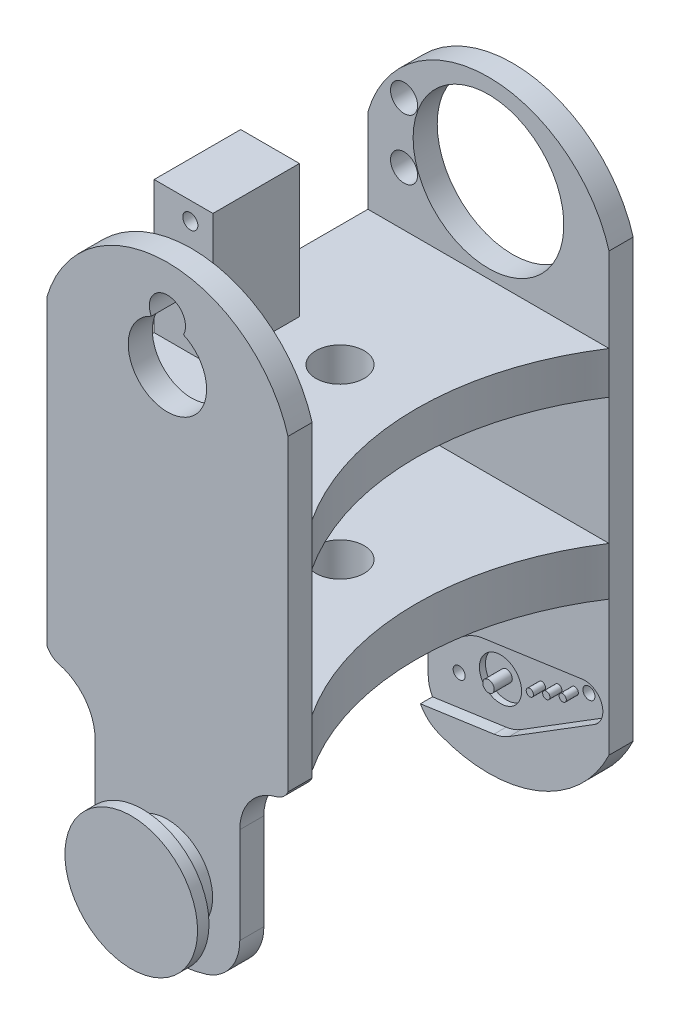
from build123d import *

# Parameters (mm, degrees)
SKETCH1_W                = 21
SKETCH1_H                = 49.25
BOSS_EXTRUDE1_DEPTH      = 20
SKETCH4_R                = 7.5
BOSS_EXTRUDE2_DEPTH      = 6
BOSS_EXTRUDE2_DEPTH_BACK = 63.25
SKETCH2_W                = 50
SKETCH2_H                = 112.412407925
SKETCH2_R                = 12.5
CUT_EXTRUDE1_DEPTH       = 110.803517703
CUT_EXTRUDE1_DEPTH_BACK  = 110.803517703
SKETCH5_W                = 20
SKETCH5_H                = 49.25
CUT_EXTRUDE2_DEPTH       = 103.250382029
CUT_EXTRUDE3_DEPTH       = 110.803517703
SKETCH7_W                = 9.75
SKETCH7_H                = 14.35
BOSS_EXTRUDE3_DEPTH      = 22
CUT_EXTRUDE4_REACH       = 99.528
SKETCH8_R                = 1.25
SKETCH9_R                = 2.25
CUT_EXTRUDE5_DEPTH       = 26.4
SKETCH10_R               = 0.6
SKETCH10_R_2             = 0.95
CUT_EXTRUDE6_DEPTH       = 2
SKETCH17_R               = 3.5
SKETCH17_R_2             = 0.95
CUT_EXTRUDE11_DEPTH      = 1
SKETCH11_R               = 1
CUT_EXTRUDE7_DEPTH       = 2
CUT_EXTRUDE8_DEPTH       = 4
CUT_EXTRUDE9_DEPTH       = 82.485524021
SKETCH14_R               = 12.5
SKETCH14_R_2             = 6.5
BOSS_EXTRUDE4_DEPTH      = 4
SKETCH16_R               = 3
CUT_EXTRUDE10_DEPTH      = 4
SKETCH18_R               = 11
BOSS_EXTRUDE5_DEPTH      = 1.9
SKETCH19_R               = 11
BOSS_EXTRUDE6_DEPTH      = 1.9
SKETCH20_R               = 4
CUT_EXTRUDE12_DEPTH      = 75
SKETCH22_R               = 45
CUT_EXTRUDE14_DEPTH      = 8


with BuildPart() as part:
    # Sketch1 → Boss-Extrude1 (new, symmetric)
    with BuildSketch(Plane.YZ):
        Polygon((-12.5, 24.625), (-12.5, 28.625), (87.5, 28.625), (87.5, 24.625), (58.5, 24.625), (58.5, -24.625), (87.5, -24.625), (87.5, -28.625), (-12.5, -28.625), (-12.5, -24.625), (22.5, -24.625), (22.5, 24.625), align=None)
        with Locations((41, 0)):
            Rectangle(SKETCH1_W, SKETCH1_H, mode=Mode.SUBTRACT)
    extrude(amount=BOSS_EXTRUDE1_DEPTH, both=True)

    # Sketch4 → Boss-Extrude2 (add, two sides)
    with BuildSketch(Plane(origin=(0, 0, -28.625), x_dir=(1, 0, 0), z_dir=(0, 0, -1))) as boss_extrude2_sk:
        with Locations(Location((0, 0, 0), (0, 0, 180))):
            Circle(SKETCH4_R)
    extrude(amount=BOSS_EXTRUDE2_DEPTH)
    extrude(boss_extrude2_sk.sketch, amount=-BOSS_EXTRUDE2_DEPTH_BACK)

    # Sketch2 → Cut-Extrude1 (cut, two sides)
    with BuildSketch(Plane(origin=(0, 0, -28.625), x_dir=(1, 0, 0), z_dir=(0, 0, -1))) as cut_extrude1_sk:
        with Locations((0, -36.293796038)):
            Rectangle(SKETCH2_W, SKETCH2_H)
        with BuildLine():
            Line((20, -0.087592075), (20, -72.5))
            ThreePointArc((20, -72.5), (0, -87.5), (-20, -72.5))
            Line((-20, -72.5), (-20, -0.087592075))
            ThreePointArc((-20, -0.087592075), (0, 12.5), (20, -0.087592075))
        make_face(mode=Mode.SUBTRACT)
        with Locations(Location((0, -72.5, 0), (0, 0, 270))):
            Circle(SKETCH2_R)
    extrude(amount=CUT_EXTRUDE1_DEPTH, mode=Mode.SUBTRACT)
    extrude(cut_extrude1_sk.sketch, amount=-CUT_EXTRUDE1_DEPTH_BACK, mode=Mode.SUBTRACT)

    # Sketch5 → Cut-Extrude2 (cut, through all)
    with BuildSketch(Plane.YZ.offset(20)):
        Rectangle(SKETCH5_W, SKETCH5_H)
    extrude(amount=-CUT_EXTRUDE2_DEPTH, mode=Mode.SUBTRACT)

    # Sketch6 → Cut-Extrude3 (cut, through all)
    with BuildSketch(Plane(origin=(0, 0, -28.625), x_dir=(1, 0, 0), z_dir=(0, 0, -1))):
        with BuildLine():
            Line((-12, 5.343628911), (-12, -13.048253679))
            ThreePointArc((-12, -13.048253679), (-13.67544468, -17.947233164), (-18, -20.794220371))
            ThreePointArc((-18, -20.794220371), (-19.196771953, -21.416398141), (-20, -22.5))
            Line((-20, -22.5), (-20, 15.418169496))
            Line((-20, 15.418169496), (0, 15.418169496))
            Line((0, 15.418169496), (0, 12.5))
            ThreePointArc((0, 12.5), (-4.185625792, 12.101526483), (-8.220875011, 10.92042185))
            ThreePointArc((-8.220875011, 10.92042185), (-10.966225922, 8.711952128), (-12, 5.343628911))
        make_face()
    extrude(amount=-CUT_EXTRUDE3_DEPTH, mode=Mode.SUBTRACT)

    # Sketch7 → Boss-Extrude3 (add)
    with BuildSketch(Plane(origin=(0, 58.5, 0), x_dir=(-1, 0, 0), z_dir=(0, 1, 0))):
        with Locations((15.125, 3.65)):
            Rectangle(SKETCH7_W, SKETCH7_H)
    extrude(amount=BOSS_EXTRUDE3_DEPTH)

    # Sketch8 → Cut-Extrude4 (cut, up to next)
    with BuildSketch(Plane(origin=(0, 0, -3.525), x_dir=(1, 0, 0), z_dir=(0, 0, -1)), mode=Mode.PRIVATE) as cut_extrude4_sk1:
        with Locations(Location((-14, -67.5, 0), (0, 0, 270))):
            Circle(SKETCH8_R)
    cut_extrude4_tool1 = extrude(cut_extrude4_sk1.sketch, amount=-CUT_EXTRUDE4_REACH, mode=Mode.PRIVATE) & part.part
    # Sketch8 → Cut-Extrude4 (cut, up to next)
    with BuildSketch(Plane(origin=(0, 0, -3.525), x_dir=(1, 0, 0), z_dir=(0, 0, -1)), mode=Mode.PRIVATE) as cut_extrude4_sk2:
        with Locations(Location((-14, -77.5, 0), (0, 0, 270))):
            Circle(SKETCH8_R)
    cut_extrude4_tool2 = extrude(cut_extrude4_sk2.sketch, amount=-CUT_EXTRUDE4_REACH, mode=Mode.PRIVATE) & part.part
    add(cut_extrude4_tool1.solids().sort_by_distance((-14, 67.5, -3.525))[0], mode=Mode.SUBTRACT)
    add(cut_extrude4_tool2.solids().sort_by_distance((-14, 77.5, -3.525))[0], mode=Mode.SUBTRACT)

    # Sketch9 → Cut-Extrude5 (cut)
    with BuildSketch(Plane(origin=(0, 0, -28.625), x_dir=(1, 0, 0), z_dir=(0, 0, -1))):
        with Locations(Location((-14, -77.5, 0), (0, 0, 180))):
            Circle(SKETCH9_R)
        with Locations(Location((-14, -67.5, 0), (0, 0, 90))):
            Circle(SKETCH9_R)
    extrude(amount=-CUT_EXTRUDE5_DEPTH, mode=Mode.SUBTRACT)

    # Sketch10 → Cut-Extrude6 (cut)
    with BuildSketch(Plane.XY.offset(-24.625)):
        with BuildLine():
            Line((-0.917974412, 6.434852211), (15.551094055, 8.784274226))
            ThreePointArc((15.551094055, 8.784274226), (18.793852416, 6.840402867), (17.559251818, 3.266906118))
            Line((17.559251818, 3.266906118), (3.433034074, -5.519445357))
            ThreePointArc((3.433034074, -5.519445357), (2.223130932, -6.108002035), (0.917974412, -6.434852211))
            Line((0.917974412, -6.434852211), (-15.551094055, -8.784274226))
            ThreePointArc((-15.551094055, -8.784274226), (-18.793852416, -6.840402867), (-17.559251818, -3.266906118))
            Line((-17.559251818, -3.266906118), (-3.433034074, 5.519445357))
            ThreePointArc((-3.433034074, 5.519445357), (-2.223130932, 6.108002035), (-0.917974412, 6.434852211))
        make_face()
        with Locations((12.309973332, 4.480463878)):
            Circle(SKETCH10_R, mode=Mode.SUBTRACT)
        with Locations((9.584864732, 3.488605462)):
            Circle(SKETCH10_R, mode=Mode.SUBTRACT)
        with Locations((6.859756132, 2.496747046)):
            Circle(SKETCH10_R, mode=Mode.SUBTRACT)
        Circle(SKETCH10_R_2, mode=Mode.SUBTRACT)
    extrude(amount=-CUT_EXTRUDE6_DEPTH, mode=Mode.SUBTRACT)

    # Sketch17 → Cut-Extrude11 (cut)
    with BuildSketch(Plane.XY.offset(-26.625)):
        Circle(SKETCH17_R)
        Circle(SKETCH17_R_2, mode=Mode.SUBTRACT)
    extrude(amount=-CUT_EXTRUDE11_DEPTH, mode=Mode.SUBTRACT)

    # Sketch11 → Cut-Extrude7 (cut)
    with BuildSketch(Plane.XY.offset(-26.625)):
        with Locations((14.659204884, 5.335514236)):
            Circle(SKETCH11_R)
        with Locations(Location((-6.859756132, -2.496747046, 0), (0, 0, 282.284944741))):
            Circle(SKETCH11_R)
    extrude(amount=-CUT_EXTRUDE7_DEPTH, mode=Mode.SUBTRACT)

    # Sketch12 → Cut-Extrude8 (cut)
    with BuildSketch(Plane.XY.offset(28.625)):
        with BuildLine():
            Line((0, -12.5), (0, -18.039119765))
            Line((0, -18.039119765), (20, -18.039119765))
            Line((20, -18.039119765), (20, 21.429096263))
            ThreePointArc((20, 21.429096263), (19.196193013, 20.360986537), (18.008206922, 19.748081074))
            ThreePointArc((18.008206922, 19.748081074), (13.678040469, 16.902328803), (12, 12))
            Line((12, 12), (12, -3.925954614))
            ThreePointArc((12, -3.925954614), (10.465352752, -8.637558778), (6.450196551, -11.541500351))
            ThreePointArc((6.450196551, -11.541500351), (3.264426341, -12.285407289), (0, -12.5))
        make_face()
    extrude(amount=-CUT_EXTRUDE8_DEPTH, mode=Mode.SUBTRACT)

    # Sketch13 → Cut-Extrude9 (cut, through all)
    with BuildSketch(Plane(origin=(0, 58.5, 0), x_dir=(-1, 0, 0), z_dir=(0, 1, 0))):
        with BuildLine():
            Line((-20, 24.625), (-20, -24.625))
            ThreePointArc((-20, -24.625), (-12.664431165, 0), (-20, 24.625))
        make_face()
    extrude(amount=-CUT_EXTRUDE9_DEPTH, mode=Mode.SUBTRACT)

    # Sketch14 → Boss-Extrude4 (add)
    with BuildSketch(Plane.XY.offset(28.625)):
        with Locations(Location((0, 72.5, 0), (0, 0, 180))):
            Circle(SKETCH14_R)
        with Locations((0, 72.5)):
            Circle(SKETCH14_R_2, mode=Mode.SUBTRACT)
    extrude(amount=-BOSS_EXTRUDE4_DEPTH)

    # Sketch16 → Cut-Extrude10 (cut)
    with BuildSketch(Plane.XY.offset(28.625)):
        with Locations((0, 79.8)):
            Circle(SKETCH16_R)
    extrude(amount=-CUT_EXTRUDE10_DEPTH, mode=Mode.SUBTRACT)

    # Sketch18 → Boss-Extrude5 (add)
    with BuildSketch(Plane.XY.offset(34.625)):
        Circle(SKETCH18_R)
    extrude(amount=-BOSS_EXTRUDE5_DEPTH)

    # Sketch19 → Boss-Extrude6 (add)
    with BuildSketch(Plane(origin=(0, 0, -34.625), x_dir=(1, 0, 0), z_dir=(0, 0, -1))):
        Circle(SKETCH19_R)
    extrude(amount=-BOSS_EXTRUDE6_DEPTH)

    # Sketch20 → Cut-Extrude12 (cut)
    with BuildSketch(Plane.XZ.offset(-22.5)):
        with Locations(Location((0, 0, 0), (0, 0, 270))):
            Circle(SKETCH20_R)
    extrude(amount=-CUT_EXTRUDE12_DEPTH, mode=Mode.SUBTRACT)

    # Sketch22 → Cut-Extrude14 (cut)
    with BuildSketch(Plane.XZ.offset(-22.5)):
        with Locations((-57.664431165, 0)):
            Circle(SKETCH22_R)
    extrude(amount=-CUT_EXTRUDE14_DEPTH, mode=Mode.SUBTRACT)


solid = part.part
